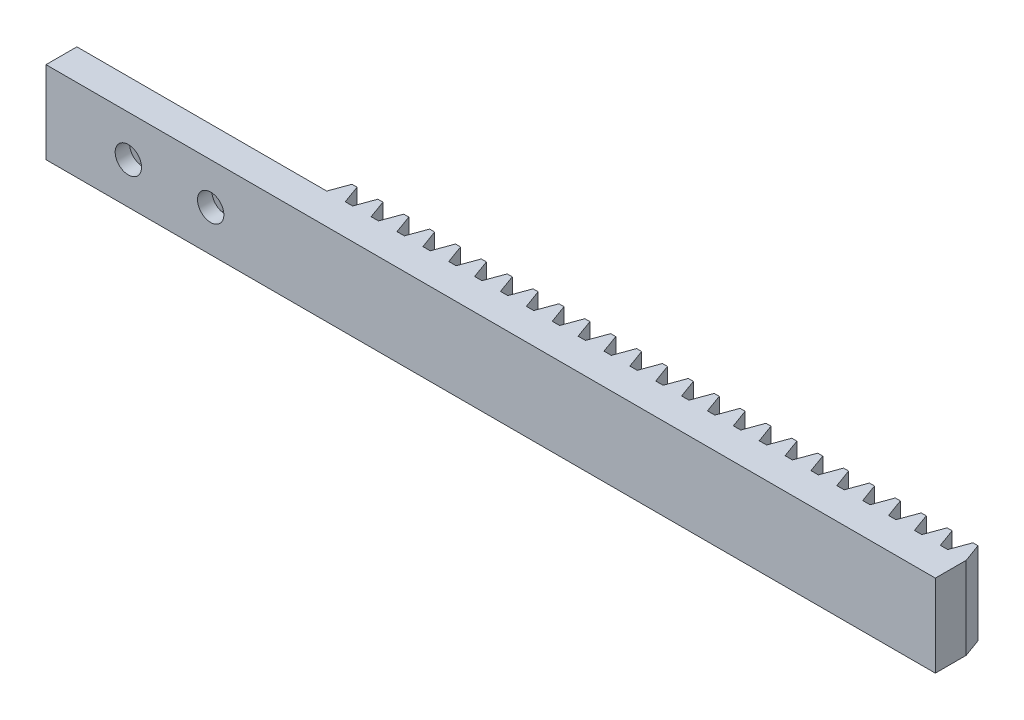
from build123d import *

# Parameters (mm, degrees)
EXTRUDE_1_DEPTH        = 10
EXTRUDE_2_DEPTH        = 10
PATTERN_LINEAR_1_COUNT = 25
PATTERN_LINEAR_1_PITCH = 3.142
SKETCH_2_R             = 1.6
CUT_EXTRUDE_1_DEPTH    = 10
CUT_EXTRUDE_2_DEPTH    = 2


with BuildPart() as part:
    # 草图1 → 凸台-拉伸1 (new body)
    with BuildSketch(Plane(origin=(0, 0, 0), x_dir=(1, 0, 0), z_dir=(0, 1, 0))):
        Polygon((0, 3.75), (0, 0), (108, 0), (108, 3.75), (105.747407554, 3.75), align=None)
    extrude(amount=EXTRUDE_1_DEPTH)

    # 草图1<5> → 凸台-拉伸2 (add)
    with BuildSketch(Plane(origin=(0, 0, 0), x_dir=(1, 0, 0), z_dir=(0, 1, 0))):
        Polygon((105.747407554, 3.75), (108, 3.75), (107.181203777, 5.999624134), (106.566203777, 5.999624134), align=None)
    extrude_2 = extrude(amount=EXTRUDE_2_DEPTH)

    # 阵列(线性)1: 凸台-拉伸2 ×25
    with Locations(*[(-i * PATTERN_LINEAR_1_PITCH, 0, 0) for i in range(1, PATTERN_LINEAR_1_COUNT)]):
        add(extrude_2)

    # 草图2 → 切除-拉伸1 (cut)
    with BuildSketch(Plane(origin=(0, 0, -3.75), x_dir=(-1, 0, 0), z_dir=(0, 0, -1))):
        with Locations((-10, 5)):
            Circle(SKETCH_2_R)
        with Locations((-20, 5)):
            Circle(SKETCH_2_R)
    extrude(amount=-CUT_EXTRUDE_1_DEPTH, mode=Mode.SUBTRACT)

    # 草图3 → 切除-拉伸2 (cut)
    with BuildSketch(Plane(origin=(0, 0, -3.75), x_dir=(-1, 0, 0), z_dir=(0, 0, -1))):
        Polygon((-21.58771324, 7.75), (-23.175426481, 5), (-21.58771324, 2.25), (-18.41228676, 2.25), (-16.824573519, 5), (-18.41228676, 7.75), align=None)
        Polygon((-11.58771324, 7.75), (-13.175426481, 5), (-11.58771324, 2.25), (-8.41228676, 2.25), (-6.824573519, 5), (-8.41228676, 7.75), align=None)
    extrude(amount=-CUT_EXTRUDE_2_DEPTH, mode=Mode.SUBTRACT)


solid = part.part
